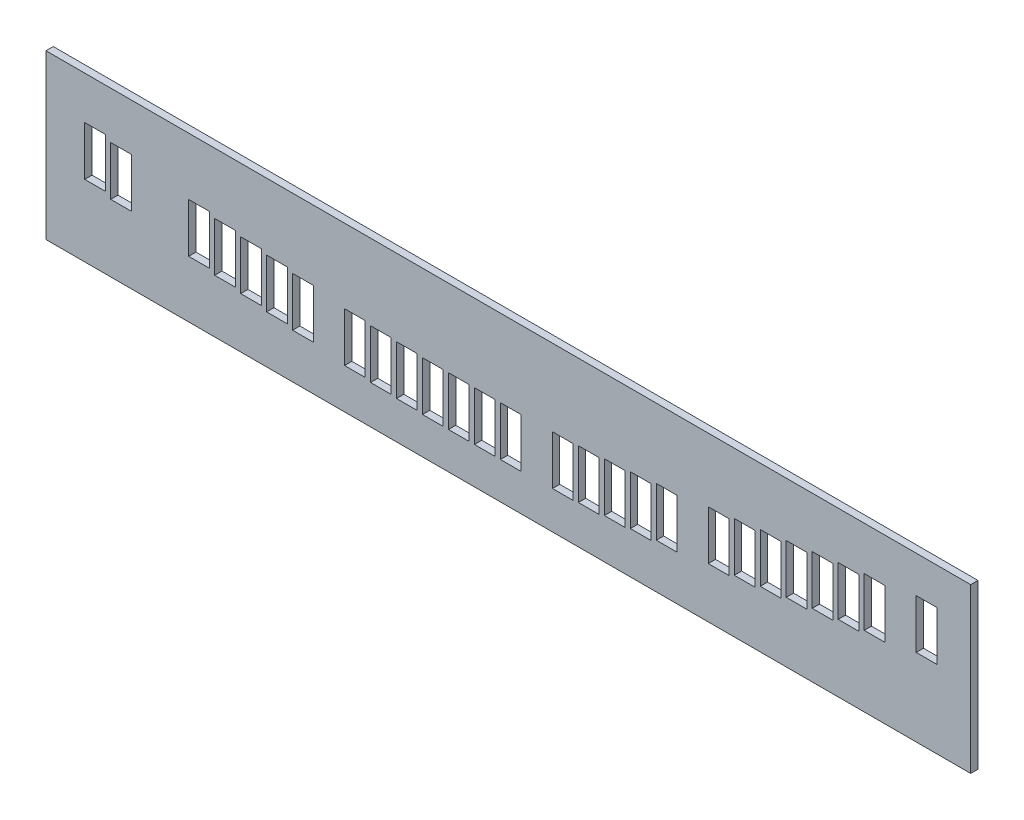
from build123d import *

# Parameters (mm, degrees)
SKETCH2_W           = 1647.9
SKETCH2_H           = 284.681734848
SKETCH2_W_2         = 36
SKETCH2_H_2         = 85.677465121
BOSS_EXTRUDE1_DEPTH = 12.7
SKETCH3_W           = 19.05
SKETCH3_H           = 284.681734848
CUT_EXTRUDE1_DEPTH  = 13.7
SKETCH4_W           = 36
SKETCH4_H           = 50.330449982
SKETCH4_H_2         = 35.349550018
CUT_EXTRUDE2_DEPTH  = 13.7


with BuildPart() as part:
    # Sketch2 → Boss-Extrude1 (new body)
    with BuildSketch(Plane.XY):
        with Locations((842.999943303, 176.189566708)):
            Rectangle(SKETCH2_W, SKETCH2_H)
        with Locations((1571.01994314, 211.688120447)):
            Rectangle(SKETCH2_W_2, SKETCH2_H_2, mode=Mode.SUBTRACT)
        with Locations((1480.459247559, 199.688120447)):
            Rectangle(SKETCH2_W_2, SKETCH2_H_2, mode=Mode.SUBTRACT)
        with Locations((1435.229386921, 193.688120447)):
            Rectangle(SKETCH2_W_2, SKETCH2_H_2, mode=Mode.SUBTRACT)
        with Locations((1390.000695887, 187.688120447)):
            Rectangle(SKETCH2_W_2, SKETCH2_H_2, mode=Mode.SUBTRACT)
        with Locations((1344.768303255, 181.688120447)):
            Rectangle(SKETCH2_W_2, SKETCH2_H_2, mode=Mode.SUBTRACT)
        with Locations((1299.538396377, 175.688120447)):
            Rectangle(SKETCH2_W_2, SKETCH2_H_2, mode=Mode.SUBTRACT)
        with Locations((1254.306140471, 169.688120446)):
            Rectangle(SKETCH2_W_2, SKETCH2_H_2, mode=Mode.SUBTRACT)
        with Locations((1209.07770281, 164.688120446)):
            Rectangle(SKETCH2_W_2, SKETCH2_H_2, mode=Mode.SUBTRACT)
        with Locations((1118.618578512, 154.688120446)):
            Rectangle(SKETCH2_W_2, SKETCH2_H_2, mode=Mode.SUBTRACT)
        with Locations((1073.383844827, 149.688120446)):
            Rectangle(SKETCH2_W_2, SKETCH2_H_2, mode=Mode.SUBTRACT)
        with Locations((1028.155686863, 146.688120446)):
            Rectangle(SKETCH2_W_2, SKETCH2_H_2, mode=Mode.SUBTRACT)
        with Locations((982.9239215, 143.688120446)):
            Rectangle(SKETCH2_W_2, SKETCH2_H_2, mode=Mode.SUBTRACT)
        with Locations((937.694704034, 142.188120446)):
            Rectangle(SKETCH2_W_2, SKETCH2_H_2, mode=Mode.SUBTRACT)
        with Locations((847.230489128, 140.688120446)):
            Rectangle(SKETCH2_W_2, SKETCH2_H_2, mode=Mode.SUBTRACT)
        with Locations((801.999943303, 140.688120446)):
            Rectangle(SKETCH2_W_2, SKETCH2_H_2, mode=Mode.SUBTRACT)
        with Locations((756.774236257, 140.688120446)):
            Rectangle(SKETCH2_W_2, SKETCH2_H_2, mode=Mode.SUBTRACT)
        with Locations((711.541406556, 140.688120446)):
            Rectangle(SKETCH2_W_2, SKETCH2_H_2, mode=Mode.SUBTRACT)
        with Locations((666.310021351, 142.188120446)):
            Rectangle(SKETCH2_W_2, SKETCH2_H_2, mode=Mode.SUBTRACT)
        with Locations((621.080803885, 143.688120446)):
            Rectangle(SKETCH2_W_2, SKETCH2_H_2, mode=Mode.SUBTRACT)
        with Locations((575.849038522, 146.688120446)):
            Rectangle(SKETCH2_W_2, SKETCH2_H_2, mode=Mode.SUBTRACT)
        with Locations((485.386146872, 154.688120446)):
            Rectangle(SKETCH2_W_2, SKETCH2_H_2, mode=Mode.SUBTRACT)
        with Locations((304.466329007, 175.688120447)):
            Rectangle(SKETCH2_W_2, SKETCH2_H_2, mode=Mode.SUBTRACT)
        with Locations((440.15644292, 159.688120446)):
            Rectangle(SKETCH2_W_2, SKETCH2_H_2, mode=Mode.SUBTRACT)
        with Locations((394.927022575, 164.688120446)):
            Rectangle(SKETCH2_W_2, SKETCH2_H_2, mode=Mode.SUBTRACT)
        with Locations((349.698584914, 169.688120446)):
            Rectangle(SKETCH2_W_2, SKETCH2_H_2, mode=Mode.SUBTRACT)
        with Locations((168.775338464, 193.688120447)):
            Rectangle(SKETCH2_W_2, SKETCH2_H_2, mode=Mode.SUBTRACT)
    extrude(amount=BOSS_EXTRUDE1_DEPTH)

    # Sketch3 → Cut-Extrude1 (cut, through all)
    with BuildSketch(Plane.XY.offset(12.7)):
        with Locations((1657.424943303, 176.189566708)):
            Rectangle(SKETCH3_W, SKETCH3_H)
        with Locations((28.574943303, 176.189566708)):
            Rectangle(SKETCH3_W, SKETCH3_H)
    extrude(amount=-CUT_EXTRUDE1_DEPTH, mode=Mode.SUBTRACT)

    # Sketch4 → Cut-Extrude2 (cut, through all)
    with BuildSketch(Plane.XY.offset(12.7)):
        with Locations((123.545338464, 218.853345438)):
            Rectangle(SKETCH4_W, SKETCH4_H)
        with Locations((123.545338464, 176.013345438)):
            Rectangle(SKETCH4_W, SKETCH4_H_2)
    extrude(amount=-CUT_EXTRUDE2_DEPTH, mode=Mode.SUBTRACT)


solid = part.part
